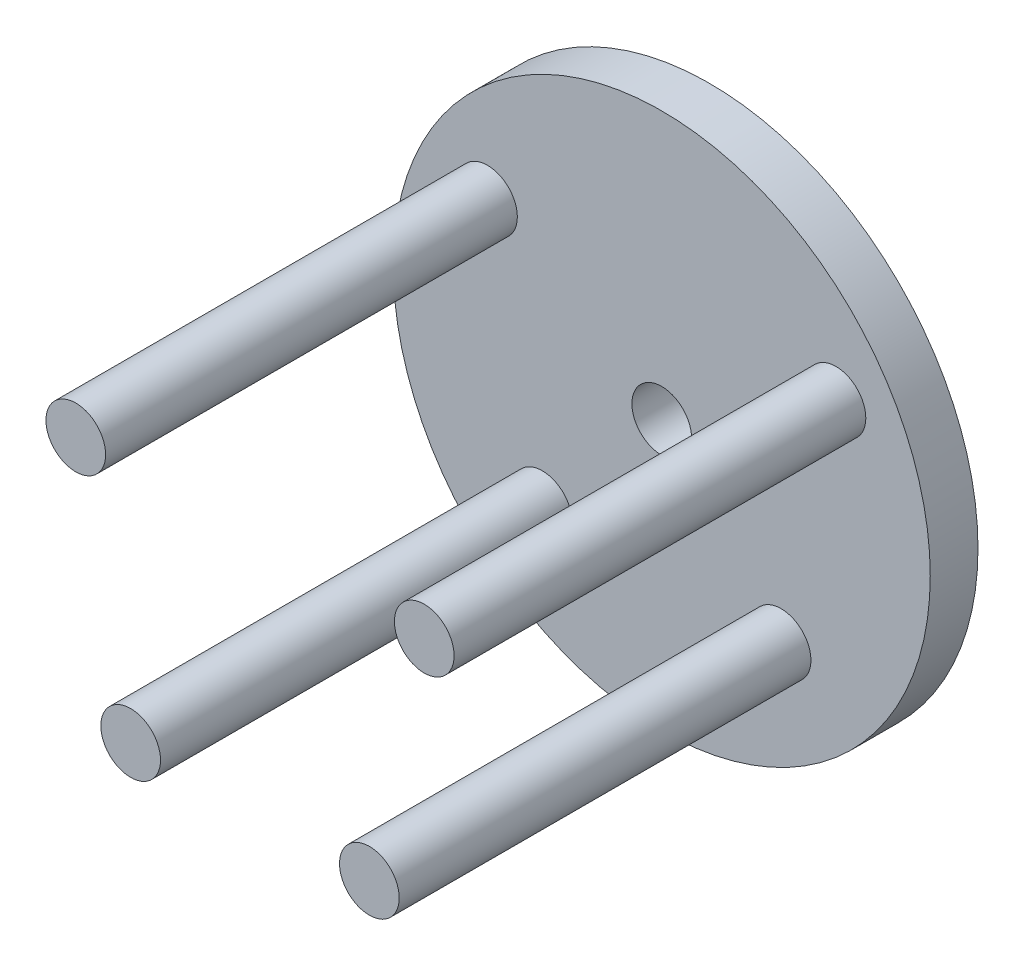
from build123d import *

# Parameters (mm, degrees)
SKETCH1_R           = 28.575
BOSS_EXTRUDE1_DEPTH = 5.08
SKETCH2_R           = 3.175
BOSS_EXTRUDE2_DEPTH = 43.815
SKETCH6_R           = 3.175
CUT_EXTRUDE2_DEPTH  = 49.895


with BuildPart() as part:
    # Sketch1 → Boss-Extrude1 (new body)
    with BuildSketch(Plane.XY):
        Circle(SKETCH1_R)
    extrude(amount=BOSS_EXTRUDE1_DEPTH)

    # Sketch2 → Boss-Extrude2 (add)
    with BuildSketch(Plane.XY.offset(5.08)):
        with Locations((-18.542, 11.1125)):
            Circle(SKETCH2_R)
        with Locations((18.542, 11.1125)):
            Circle(SKETCH2_R)
        with Locations((-12.7, -14.125569529)):
            Circle(SKETCH2_R)
        with Locations((12.7, -14.125569529)):
            Circle(SKETCH2_R)
    extrude(amount=BOSS_EXTRUDE2_DEPTH)

    # Sketch6 → Cut-Extrude2 (cut, through all)
    with BuildSketch(Plane(origin=(0, 0, 0), x_dir=(-1, 0, 0), z_dir=(0, 0, -1))):
        Circle(SKETCH6_R)
    extrude(amount=-CUT_EXTRUDE2_DEPTH, mode=Mode.SUBTRACT)


solid = part.part
